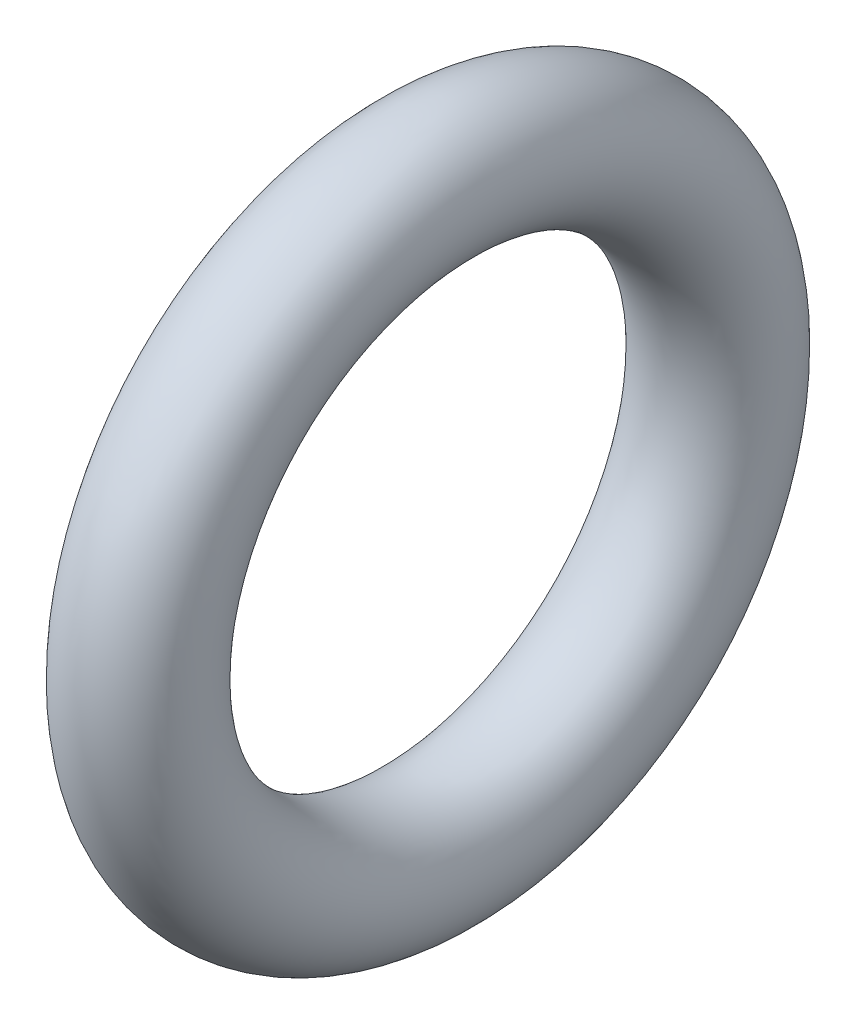
from build123d import *

# Parameters (mm, degrees)
SKIZZE1_R = 1.3


with BuildPart() as part:
    # Skizze1 → Rotation1 (revolve)
    with BuildSketch(Plane.XY):
        with Locations((0, 5.8)):
            Circle(SKIZZE1_R)
    revolve(axis=Axis((-5.518776228, 0, 0), (-1, 0, 0)))


solid = part.part
